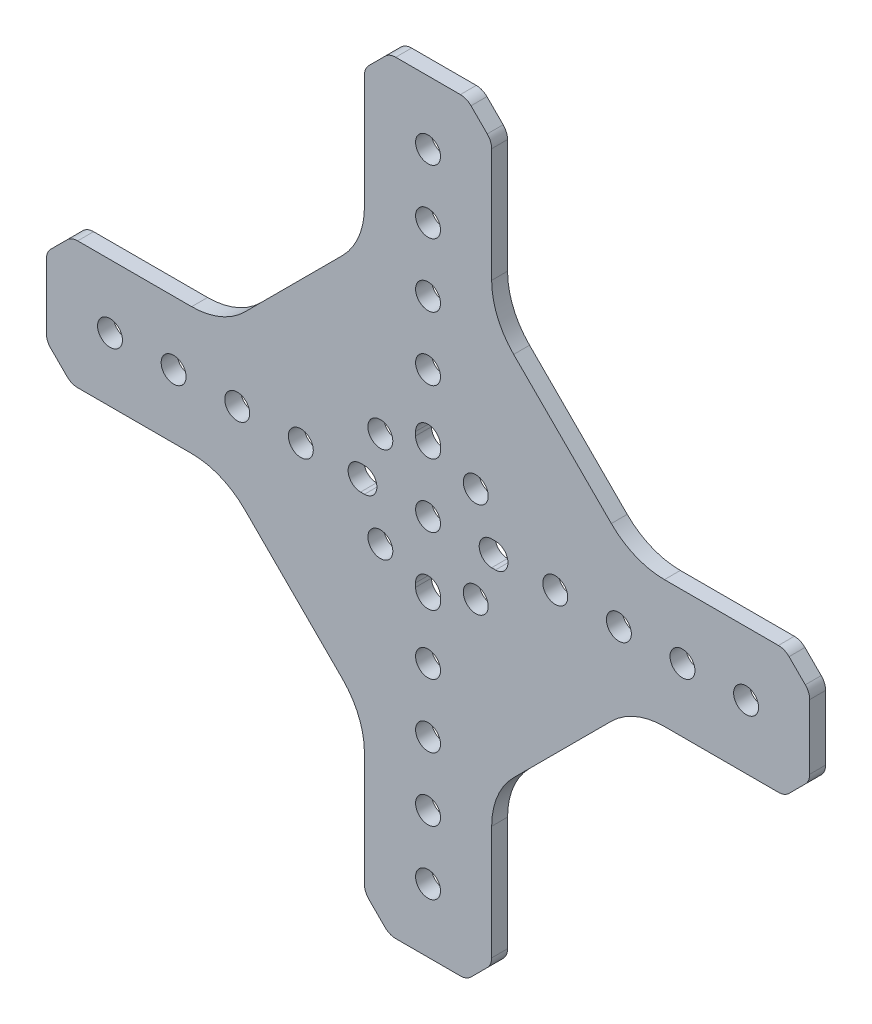
from build123d import *

# Parameters (mm, degrees)
SKETCH1_R           = 2.4892
BOSS_EXTRUDE1_DEPTH = 3.175


with BuildPart() as part:
    # Sketch1 → Boss-Extrude1 (new body)
    with BuildSketch(Plane(origin=(0, 0, 0), x_dir=(-1, 0, 0), z_dir=(0, 0, -1))):
        with BuildLine():
            Line((-59.897474683, 25.4), (-82.657359313, 25.4))
            ThreePointArc((-82.657359313, 25.4), (-83.80540961, 25.171638598), (-84.778679656, 24.521320344))
            Line((-84.778679656, 24.521320344), (-88.021320344, 21.278679656))
            ThreePointArc((-88.021320344, 21.278679656), (-88.671638598, 20.30540961), (-88.9, 19.157359313))
            Line((-88.9, 19.157359313), (-88.9, 6.242640687))
            ThreePointArc((-88.9, 6.242640687), (-88.671638598, 5.09459039), (-88.021320344, 4.121320344))
            Line((-88.021320344, 4.121320344), (-84.778679656, 0.878679656))
            ThreePointArc((-84.778679656, 0.878679656), (-83.80540961, 0.228361402), (-82.657359313, 0))
            Line((-82.657359313, 0), (-59.897474683, 0))
            ThreePointArc((-59.897474683, 0), (-54.157223198, -1.141807012), (-49.290872965, -4.393398282))
            Line((-49.290872965, -4.393398282), (-29.793398282, -23.890872965))
            ThreePointArc((-29.793398282, -23.890872965), (-26.541807012, -28.757223198), (-25.4, -34.497474683))
            Line((-25.4, -34.497474683), (-25.4, -57.257359313))
            ThreePointArc((-25.4, -57.257359313), (-25.171638598, -58.40540961), (-24.521320344, -59.378679656))
            Line((-24.521320344, -59.378679656), (-21.278679656, -62.621320344))
            ThreePointArc((-21.278679656, -62.621320344), (-20.30540961, -63.271638598), (-19.157359313, -63.5))
            Line((-19.157359313, -63.5), (-6.242640687, -63.5))
            ThreePointArc((-6.242640687, -63.5), (-5.09459039, -63.271638598), (-4.121320344, -62.621320344))
            Line((-4.121320344, -62.621320344), (-0.878679656, -59.378679656))
            ThreePointArc((-0.878679656, -59.378679656), (-0.228361402, -58.40540961), (0, -57.257359313))
            Line((0, -57.257359313), (0, -34.497474683))
            ThreePointArc((0, -34.497474683), (1.141807012, -28.757223198), (4.393398282, -23.890872965))
            Line((4.393398282, -23.890872965), (23.890872965, -4.393398282))
            ThreePointArc((23.890872965, -4.393398282), (28.757223198, -1.141807012), (34.497474683, 0))
            Line((34.497474683, 0), (57.257359313, 0))
            ThreePointArc((57.257359313, 0), (58.40540961, 0.228361402), (59.378679656, 0.878679656))
            Line((59.378679656, 0.878679656), (62.621320344, 4.121320344))
            ThreePointArc((62.621320344, 4.121320344), (63.271638598, 5.09459039), (63.5, 6.242640687))
            Line((63.5, 6.242640687), (63.5, 19.157359313))
            ThreePointArc((63.5, 19.157359313), (63.271638598, 20.30540961), (62.621320344, 21.278679656))
            Line((62.621320344, 21.278679656), (59.378679656, 24.521320344))
            ThreePointArc((59.378679656, 24.521320344), (58.40540961, 25.171638598), (57.257359313, 25.4))
            Line((57.257359313, 25.4), (34.497474683, 25.4))
            ThreePointArc((34.497474683, 25.4), (28.757223198, 26.541807012), (23.890872965, 29.793398282))
            Line((23.890872965, 29.793398282), (4.393398282, 49.290872965))
            ThreePointArc((4.393398282, 49.290872965), (1.141807012, 54.157223198), (0, 59.897474683))
            Line((0, 59.897474683), (0, 82.657359313))
            ThreePointArc((0, 82.657359313), (-0.228361402, 83.80540961), (-0.878679656, 84.778679656))
            Line((-0.878679656, 84.778679656), (-4.121320344, 88.021320344))
            ThreePointArc((-4.121320344, 88.021320344), (-5.09459039, 88.671638598), (-6.242640687, 88.9))
            Line((-6.242640687, 88.9), (-19.157359313, 88.9))
            ThreePointArc((-19.157359313, 88.9), (-20.30540961, 88.671638598), (-21.278679656, 88.021320344))
            Line((-21.278679656, 88.021320344), (-24.521320344, 84.778679656))
            ThreePointArc((-24.521320344, 84.778679656), (-25.171638598, 83.80540961), (-25.4, 82.657359313))
            Line((-25.4, 82.657359313), (-25.4, 59.897474683))
            ThreePointArc((-25.4, 59.897474683), (-26.541807012, 54.157223198), (-29.793398282, 49.290872965))
            Line((-29.793398282, 49.290872965), (-49.290872965, 29.793398282))
            ThreePointArc((-49.290872965, 29.793398282), (-54.157223198, 26.541807012), (-59.897474683, 25.4))
        make_face()
        with Locations((-12.7, -12.7)):
            Circle(SKETCH1_R, mode=Mode.SUBTRACT)
        with Locations((-12.7, -38.1)):
            Circle(SKETCH1_R, mode=Mode.SUBTRACT)
        with Locations((-12.7, -25.4)):
            Circle(SKETCH1_R, mode=Mode.SUBTRACT)
        with Locations((-12.7, -50.8)):
            Circle(SKETCH1_R, mode=Mode.SUBTRACT)
        with Locations((-12.7, 12.7)):
            Circle(SKETCH1_R, mode=Mode.SUBTRACT)
        with Locations((-63.5, 12.7)):
            Circle(SKETCH1_R, mode=Mode.SUBTRACT)
        with Locations((-38.1, 12.7)):
            Circle(SKETCH1_R, mode=Mode.SUBTRACT)
        with Locations((-76.2, 12.7)):
            Circle(SKETCH1_R, mode=Mode.SUBTRACT)
        with Locations((-50.8, 12.7)):
            Circle(SKETCH1_R, mode=Mode.SUBTRACT)
        with Locations((25.4, 12.7)):
            Circle(SKETCH1_R, mode=Mode.SUBTRACT)
        with Locations((50.8, 12.7)):
            Circle(SKETCH1_R, mode=Mode.SUBTRACT)
        with Locations((12.7, 12.7)):
            Circle(SKETCH1_R, mode=Mode.SUBTRACT)
        with Locations((38.1, 12.7)):
            Circle(SKETCH1_R, mode=Mode.SUBTRACT)
        with Locations((-12.7, 50.8)):
            Circle(SKETCH1_R, mode=Mode.SUBTRACT)
        with Locations((-12.7, 63.5)):
            Circle(SKETCH1_R, mode=Mode.SUBTRACT)
        with Locations((-12.7, 38.1)):
            Circle(SKETCH1_R, mode=Mode.SUBTRACT)
        with Locations((-12.7, 76.2)):
            Circle(SKETCH1_R, mode=Mode.SUBTRACT)
        with Locations((-3.175, 3.175)):
            Circle(SKETCH1_R, mode=Mode.SUBTRACT)
        with Locations((-22.225, 3.175)):
            Circle(SKETCH1_R, mode=Mode.SUBTRACT)
        with Locations((-22.225, 22.225)):
            Circle(SKETCH1_R, mode=Mode.SUBTRACT)
        with Locations((-3.175, 22.225)):
            Circle(SKETCH1_R, mode=Mode.SUBTRACT)
        with BuildLine():
            Line((0, 15.1892), (0.770384182, 15.1892))
            ThreePointArc((0.770384182, 15.1892), (3.259584182, 12.7), (0.770384182, 10.2108))
            Line((0.770384182, 10.2108), (0, 10.2108))
            ThreePointArc((0, 10.2108), (-2.4892, 12.7), (0, 15.1892))
        make_face(mode=Mode.SUBTRACT)
        with BuildLine():
            Line((-26.170384182, 15.1892), (-25.4, 15.1892))
            ThreePointArc((-25.4, 15.1892), (-22.9108, 12.7), (-25.4, 10.2108))
            Line((-25.4, 10.2108), (-26.170384182, 10.2108))
            ThreePointArc((-26.170384182, 10.2108), (-28.659584182, 12.7), (-26.170384182, 15.1892))
        make_face(mode=Mode.SUBTRACT)
        with BuildLine():
            Line((-15.1892, -0.770384182), (-15.1892, 0))
            ThreePointArc((-15.1892, 0), (-12.7, 2.4892), (-10.2108, 0))
            Line((-10.2108, 0), (-10.2108, -0.770384182))
            ThreePointArc((-10.2108, -0.770384182), (-12.7, -3.259584182), (-15.1892, -0.770384182))
        make_face(mode=Mode.SUBTRACT)
        with BuildLine():
            Line((-10.2108, 26.170384182), (-10.2108, 25.4))
            ThreePointArc((-10.2108, 25.4), (-12.7, 22.9108), (-15.1892, 25.4))
            Line((-15.1892, 25.4), (-15.1892, 26.170384182))
            ThreePointArc((-15.1892, 26.170384182), (-12.7, 28.659584182), (-10.2108, 26.170384182))
        make_face(mode=Mode.SUBTRACT)
    extrude(amount=-BOSS_EXTRUDE1_DEPTH)


solid = part.part
